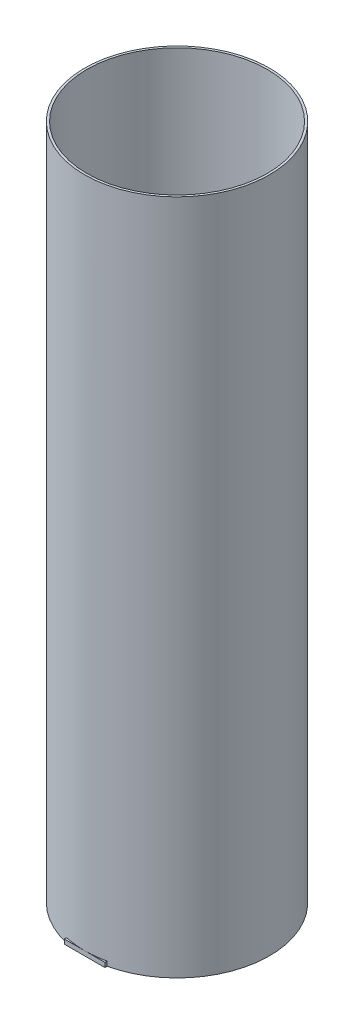
from build123d import *

# Parameters (mm, degrees)
SKETCH1_R           = 52.07
SKETCH1_R_2         = 50.8
BOSS_EXTRUDE1_DEPTH = 381
BOSS_EXTRUDE2_DEPTH = 2.54


with BuildPart() as part:
    # Sketch1 → Boss-Extrude1 (new body)
    with BuildSketch(Plane(origin=(0, 0, 0), x_dir=(1, 0, 0), z_dir=(0, 1, 0))):
        Circle(SKETCH1_R)
        Circle(SKETCH1_R_2, mode=Mode.SUBTRACT)
    extrude(amount=BOSS_EXTRUDE1_DEPTH)

    # Sketch2 → Boss-Extrude2 (add)
    with BuildSketch(Plane.XZ):
        with BuildLine():
            ThreePointArc((-11.43, 50.8), (-5.750169563, 51.751526064), (0, 52.07))
            Line((0, 52.07), (-11.43, 52.07))
            Line((-11.43, 52.07), (-11.43, 50.8))
        make_face()
        with BuildLine():
            Line((11.43, 52.07), (0, 52.07))
            ThreePointArc((0, 52.07), (5.750169563, 51.751526064), (11.43, 50.8))
            Line((11.43, 50.8), (11.43, 52.07))
        make_face()
    extrude(amount=-BOSS_EXTRUDE2_DEPTH)


solid = part.part
